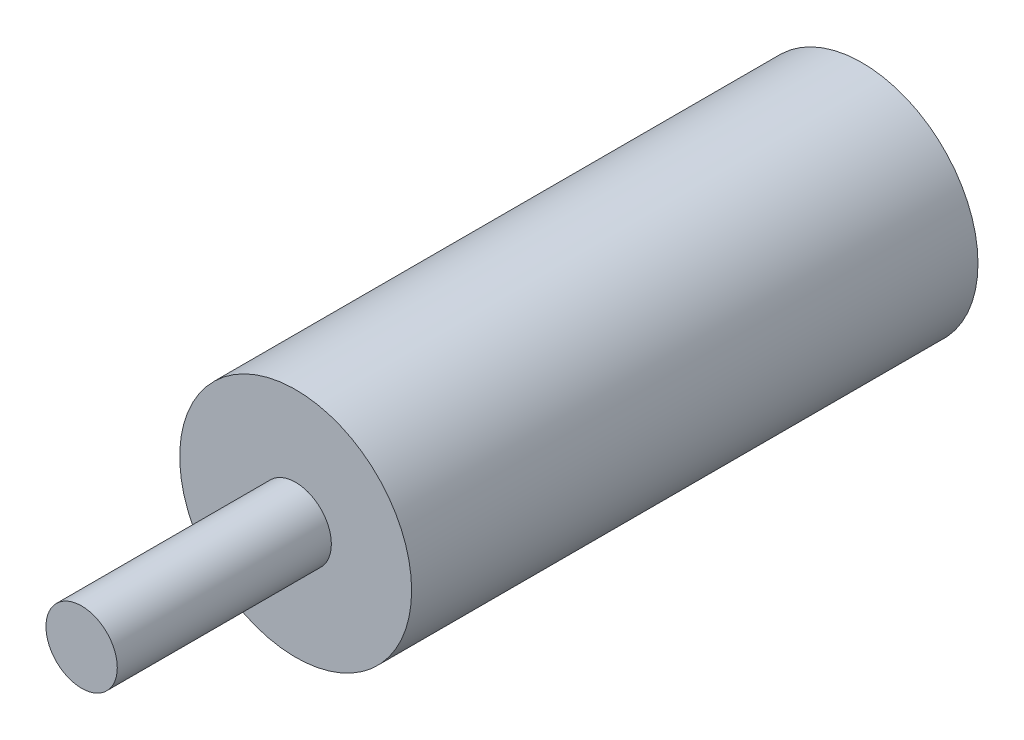
from build123d import *

# Parameters (mm, degrees)
SKETCH1_R        = 26
SKETCH1_R_2      = 8
EXTRUSION1_DEPTH = 127
SKETCH2_R        = 8
EXTRUSION2_DEPTH = 175


with BuildPart() as part:
    # Sketch1 → Extrusion1 (new body)
    with BuildSketch(Plane.XY):
        Circle(SKETCH1_R)
        Circle(SKETCH1_R_2, mode=Mode.SUBTRACT)
    extrude(amount=EXTRUSION1_DEPTH)

    # Sketch2 → Extrusion2 (add)
    with BuildSketch(Plane.XY):
        Circle(SKETCH2_R)
    extrude(amount=EXTRUSION2_DEPTH)


solid = part.part
